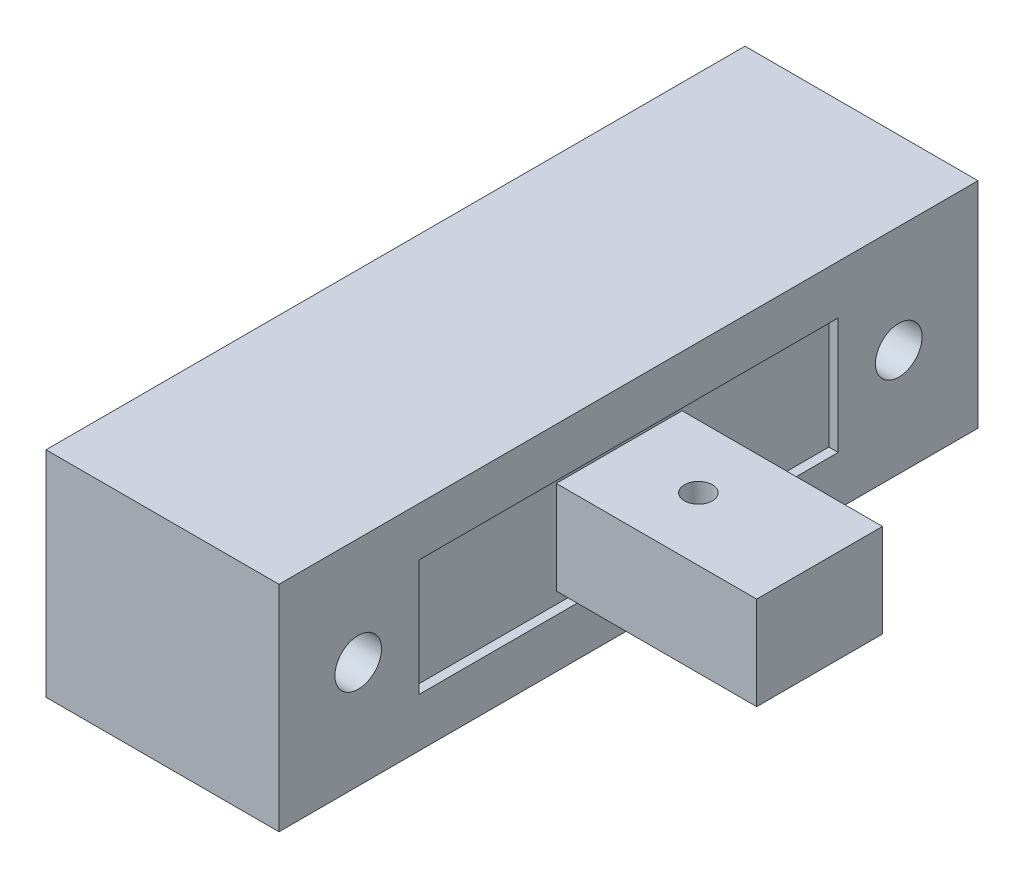
from build123d import *

# Parameters (mm, degrees)
SKETCH_1_W          = 10
SKETCH_1_H          = 30
EXTRUDE_1_DEPTH     = 4.6
SKETCH_2_W          = 18
SKETCH_2_H          = 5
CUT_EXTRUDE_1_DEPTH = 0.4
SKETCH_3_W          = 5.4
SKETCH_3_H          = 4
EXTRUDE_2_DEPTH     = 8.6
SKETCH_4_R          = 0.6
CUT_EXTRUDE_2_DEPTH = 4
SKETCH_5_R          = 1
CUT_EXTRUDE_3_DEPTH = 11


with BuildPart() as part:
    # 草图1 → 凸台-拉伸1 (new body, symmetric)
    with BuildSketch(Plane(origin=(0, 0, 0), x_dir=(1, 0, 0), z_dir=(0, 1, 0))):
        Rectangle(SKETCH_1_W, SKETCH_1_H)
    extrude(amount=EXTRUDE_1_DEPTH, both=True)

    # 草图2 → 切除-拉伸1 (cut)
    with BuildSketch(Plane(origin=(5, 0, 0), x_dir=(0, 0, -1), z_dir=(1, 0, 0))):
        Rectangle(SKETCH_2_W, SKETCH_2_H)
    extrude(amount=-CUT_EXTRUDE_1_DEPTH, mode=Mode.SUBTRACT)

    # 草图3 → 凸台-拉伸2 (add)
    with BuildSketch(Plane(origin=(4.6, 0, 0), x_dir=(0, 0, -1), z_dir=(1, 0, 0))):
        Rectangle(SKETCH_3_W, SKETCH_3_H)
    extrude(amount=EXTRUDE_2_DEPTH)

    # 草图4 → 切除-拉伸2 (cut)
    with BuildSketch(Plane(origin=(0, 2, 0), x_dir=(1, 0, 0), z_dir=(0, 1, 0))):
        with Locations((8, 0)):
            Circle(SKETCH_4_R)
    extrude(amount=-CUT_EXTRUDE_2_DEPTH, mode=Mode.SUBTRACT)

    # 草图5 → 切除-拉伸3 (cut, through all)
    with BuildSketch(Plane(origin=(5, 0, 0), x_dir=(0, 0, -1), z_dir=(1, 0, 0))):
        with Locations((11.6, 0)):
            Circle(SKETCH_5_R)
        with Locations((-11.6, 0)):
            Circle(SKETCH_5_R)
    extrude(amount=-CUT_EXTRUDE_3_DEPTH, mode=Mode.SUBTRACT)


solid = part.part
